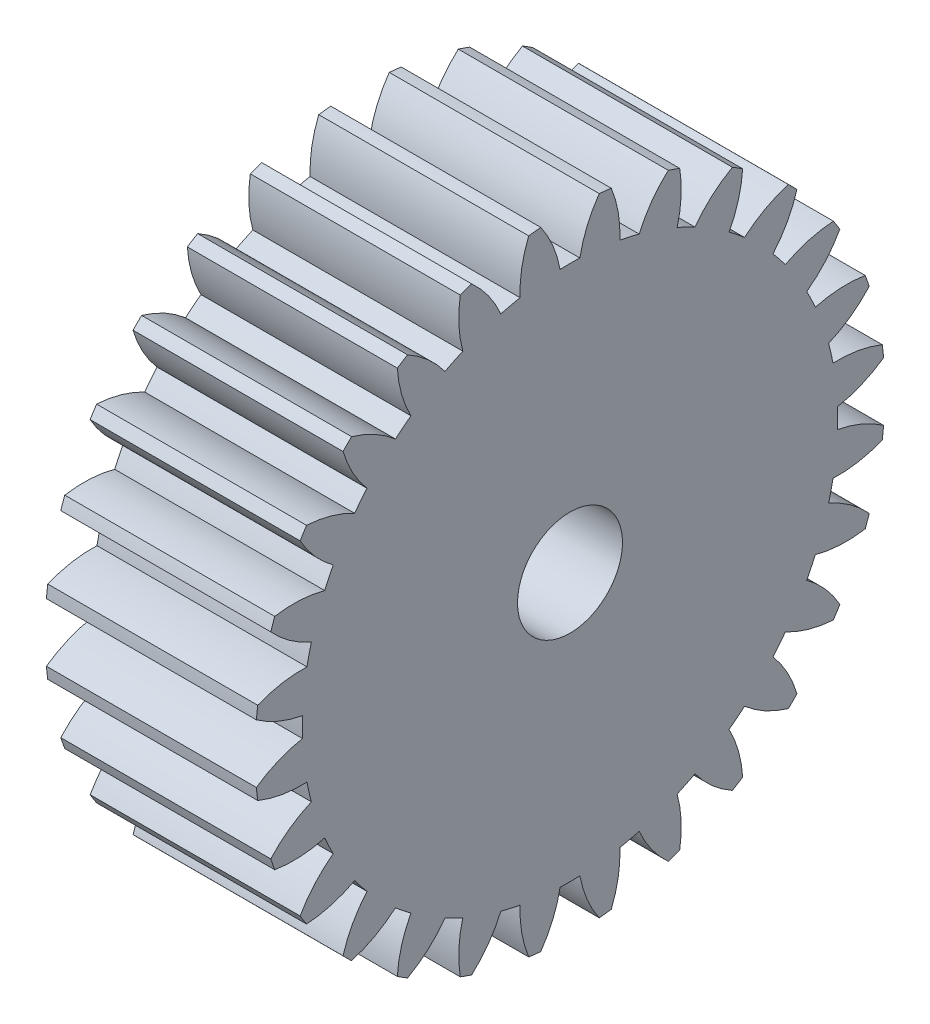
from build123d import *

# Parameters (mm, degrees)
BASPROSKE_W     = 10
BASPROSKE_H     = 15
TOOTHCUT_DEPTH  = 24.452078799
TEETHCUTS_COUNT = 28
TEETHCUTS_ANGLE = 347.142857143
BORSKE_R        = 2.5
BORE_DEPTH      = 50.0000508


with BuildPart() as part:
    # BasProSke → Base-Revolve (revolve)
    with BuildSketch(Plane(origin=(0, 0, 0), x_dir=(1, 0, 0), z_dir=(0, 1, 0)), mode=Mode.PRIVATE) as base_revolve_sk:
        with Locations((5, 7.5)):
            Rectangle(BASPROSKE_W, BASPROSKE_H)
    revolve(base_revolve_sk.sketch.rotate(Axis((-10, 0, 0), (1, 0, 0)), 180), axis=Axis((-10, 0, 0), (1, 0, 0)))

    # TooCutSke → ToothCut (cut, through all)
    with BuildSketch(Plane(origin=(0, 0, 0), x_dir=(0, 0, -1), z_dir=(1, 0, 0))):
        with BuildLine():
            ThreePointArc((0.471336039, 12.740284272), (0, 12.749), (-0.471336039, 12.740284272))
            ThreePointArc((-0.471336039, 12.740284272), (-0.81983923, 13.900763331), (-1.409805137, 14.959114099))
            ThreePointArc((-1.409805137, 14.959114099), (0, 15.0254), (1.409805137, 14.959114099))
            ThreePointArc((1.409805137, 14.959114099), (0.81983923, 13.900763331), (0.471336039, 12.740284272))
        make_face()
    toothcut = extrude(amount=TOOTHCUT_DEPTH, mode=Mode.SUBTRACT)

    # TeethCuts: ToothCut ×28 about axis
    teethcuts_axis = Axis((-10, 0, 0), (1, 0, 0))
    for i in range(1, TEETHCUTS_COUNT):
        add(toothcut.rotate(teethcuts_axis, i * TEETHCUTS_ANGLE / (TEETHCUTS_COUNT - 1)), mode=Mode.SUBTRACT)

    # BorSke → Bore (cut, symmetric)
    with BuildSketch(Plane(origin=(0, 0, 0), x_dir=(0, 0, -1), z_dir=(1, 0, 0))):
        with Locations(Location((0, 0, 0), (0, 0, 180))):
            Circle(BORSKE_R)
    extrude(amount=BORE_DEPTH, both=True, mode=Mode.SUBTRACT)


solid = part.part
